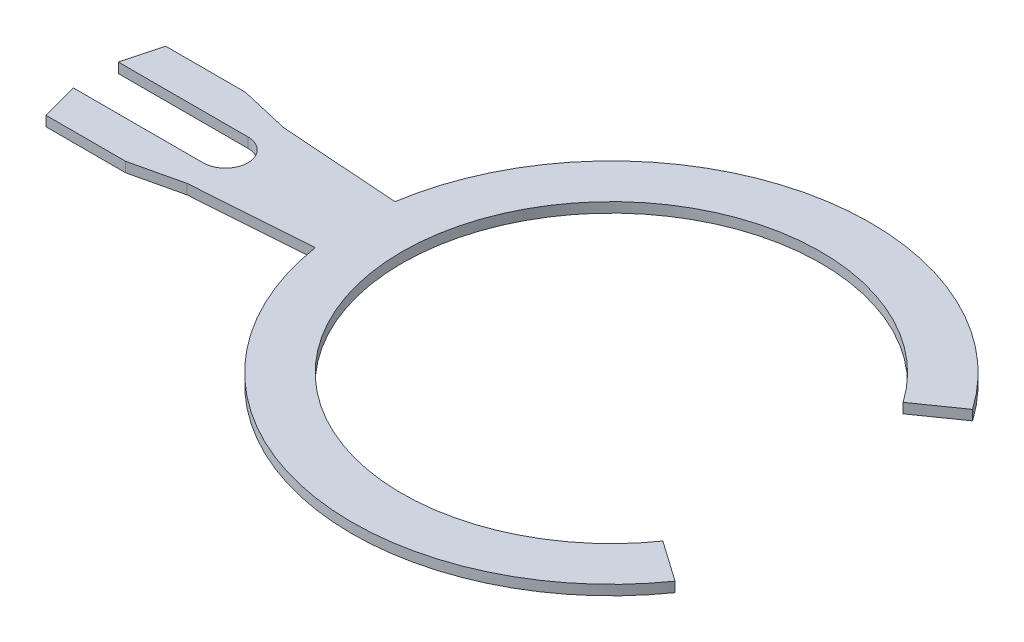
from build123d import *

# Parameters (mm, degrees)
BOSS_EXTRUDE1_DEPTH = 0.1


with BuildPart() as part:
    # Sketch1 → Boss-Extrude1 (new body)
    with BuildSketch(Plane.XZ.offset(0.2)):
        with BuildLine():
            Line((1.720219293, 1.204510516), (2.129795315, 1.491298735))
            ThreePointArc((2.129795315, 1.491298735), (-0.588190986, 2.532593802), (-2.569046516, 0.4))
            Line((-2.569046516, 0.4), (-3.769046516, 0.483912174))
            Line((-3.769046516, 0.483912174), (-4.269046516, 0.6))
            Line((-4.269046516, 0.6), (-5.068565569, 0.6))
            Line((-5.068565569, 0.6), (-5.169046516, 0.225))
            Line((-5.169046516, 0.225), (-3.869046516, 0.225))
            ThreePointArc((-3.869046516, 0.225), (-3.644046516, 0), (-3.869046516, -0.225))
            Line((-3.869046516, -0.225), (-5.169046516, -0.225))
            Line((-5.169046516, -0.225), (-5.068565569, -0.6))
            Line((-5.068565569, -0.6), (-4.269046516, -0.6))
            Line((-4.269046516, -0.6), (-3.769046516, -0.483912174))
            Line((-3.769046516, -0.483912174), (-2.569046516, -0.4))
            ThreePointArc((-2.569046516, -0.4), (-0.588190986, -2.532593802), (2.129795315, -1.491298735))
            Line((2.129795315, -1.491298735), (1.720219293, -1.204510516))
            ThreePointArc((1.720219293, -1.204510516), (-2.1, 0), (1.720219293, 1.204510516))
        make_face()
    extrude(amount=-BOSS_EXTRUDE1_DEPTH)


solid = part.part
